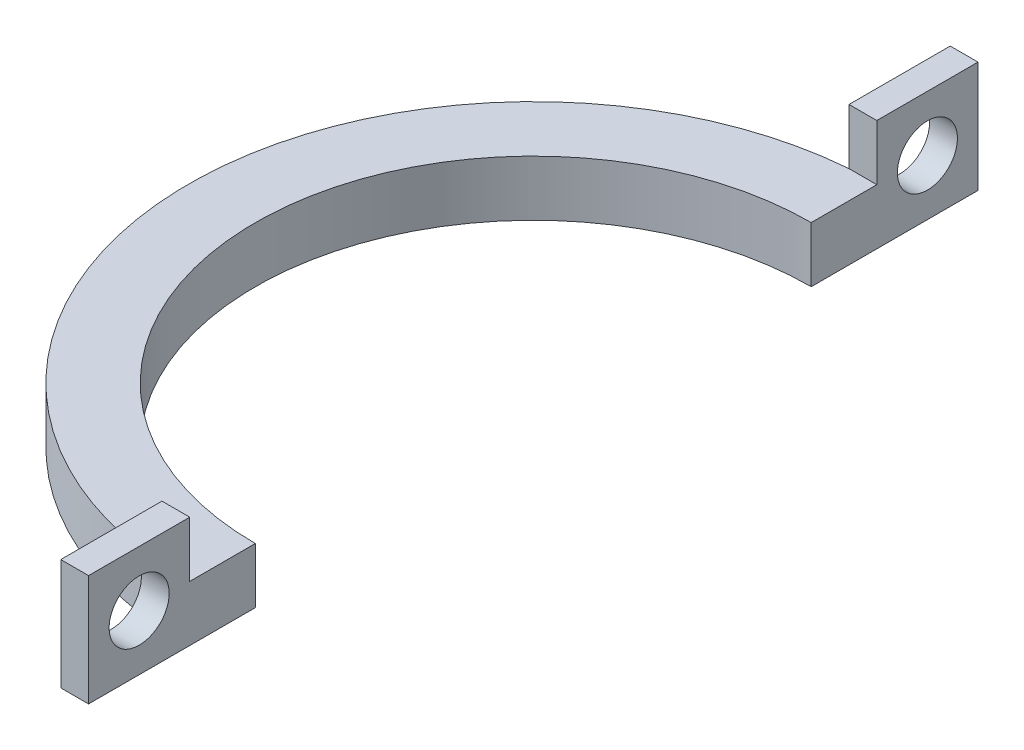
from build123d import *

# Parameters (mm, degrees)
BOSS_EXTRUDE1_DEPTH = 5
SKETCH2_W           = 2.5
SKETCH2_H           = 9.100970889
BOSS_EXTRUDE2_DEPTH = 5
CUT_EXTRUDE1_REACH  = 4.5
SKETCH3_R           = 2.7


with BuildPart() as part:
    # Sketch1 → Boss-Extrude1 (new body)
    with BuildSketch(Plane(origin=(0, 0, 0), x_dir=(1, 0, 0), z_dir=(0, 1, 0))):
        with BuildLine():
            Line((-2.5, -30.899029111), (-2.5, -24.874685928))
            ThreePointArc((-2.5, -24.874685928), (-25, 0), (-2.5, 24.874685928))
            Line((-2.5, 24.874685928), (-2.5, 30.899029111))
            ThreePointArc((-2.5, 30.899029111), (-31, 0), (-2.5, -30.899029111))
        make_face()
        with BuildLine():
            Line((0, -31), (0, -25))
            ThreePointArc((0, -25), (-1.251569376, -24.968651828), (-2.5, -24.874685928))
            Line((-2.5, -24.874685928), (-2.5, -30.899029111))
            ThreePointArc((-2.5, -30.899029111), (-1.251019097, -30.974746992), (0, -31))
        make_face()
        with BuildLine():
            Line((0, -40), (0, -31))
            ThreePointArc((0, -31), (-1.251019097, -30.974746992), (-2.5, -30.899029111))
            Line((-2.5, -30.899029111), (-2.5, -40))
            Line((-2.5, -40), (0, -40))
        make_face()
        with BuildLine():
            Line((-2.5, 30.899029111), (-2.5, 24.874685928))
            ThreePointArc((-2.5, 24.874685928), (-1.251569376, 24.968651828), (0, 25))
            Line((0, 25), (0, 31))
            ThreePointArc((0, 31), (-1.251019097, 30.974746992), (-2.5, 30.899029111))
        make_face()
        with BuildLine():
            Line((-2.5, 40), (-2.5, 30.899029111))
            ThreePointArc((-2.5, 30.899029111), (-1.251019097, 30.974746992), (0, 31))
            Line((0, 31), (0, 40))
            Line((0, 40), (-2.5, 40))
        make_face()
    extrude(amount=BOSS_EXTRUDE1_DEPTH)

    # Sketch2 → Boss-Extrude2 (add)
    with BuildSketch(Plane(origin=(0, 5, 0), x_dir=(1, 0, 0), z_dir=(0, 1, 0))):
        with Locations((-1.25, 35.449514556)):
            Rectangle(SKETCH2_W, SKETCH2_H)
        with Locations((-1.25, -35.449514556)):
            Rectangle(SKETCH2_W, SKETCH2_H)
    extrude(amount=BOSS_EXTRUDE2_DEPTH)

    # Sketch3 → Cut-Extrude1 (cut, up to next)
    with BuildSketch(Plane.ZY.offset(2.5), mode=Mode.PRIVATE) as cut_extrude1_sk1:
        with Locations((-35.449514555, 5)):
            Circle(SKETCH3_R)
    cut_extrude1_tool1 = extrude(cut_extrude1_sk1.sketch, amount=-CUT_EXTRUDE1_REACH, mode=Mode.PRIVATE) & part.part
    add(cut_extrude1_tool1.solids().sort_by_distance((-2.5, 5, -35.449515))[0], mode=Mode.SUBTRACT)
    # Sketch3 → Cut-Extrude1 (cut, up to next)
    with BuildSketch(Plane.ZY.offset(2.5), mode=Mode.PRIVATE) as cut_extrude1_sk2:
        with Locations((35.449514555, 5)):
            Circle(SKETCH3_R)
    cut_extrude1_tool2 = extrude(cut_extrude1_sk2.sketch, amount=-CUT_EXTRUDE1_REACH, mode=Mode.PRIVATE) & part.part
    add(cut_extrude1_tool2.solids().sort_by_distance((-2.5, 5, 35.449515))[0], mode=Mode.SUBTRACT)


solid = part.part
